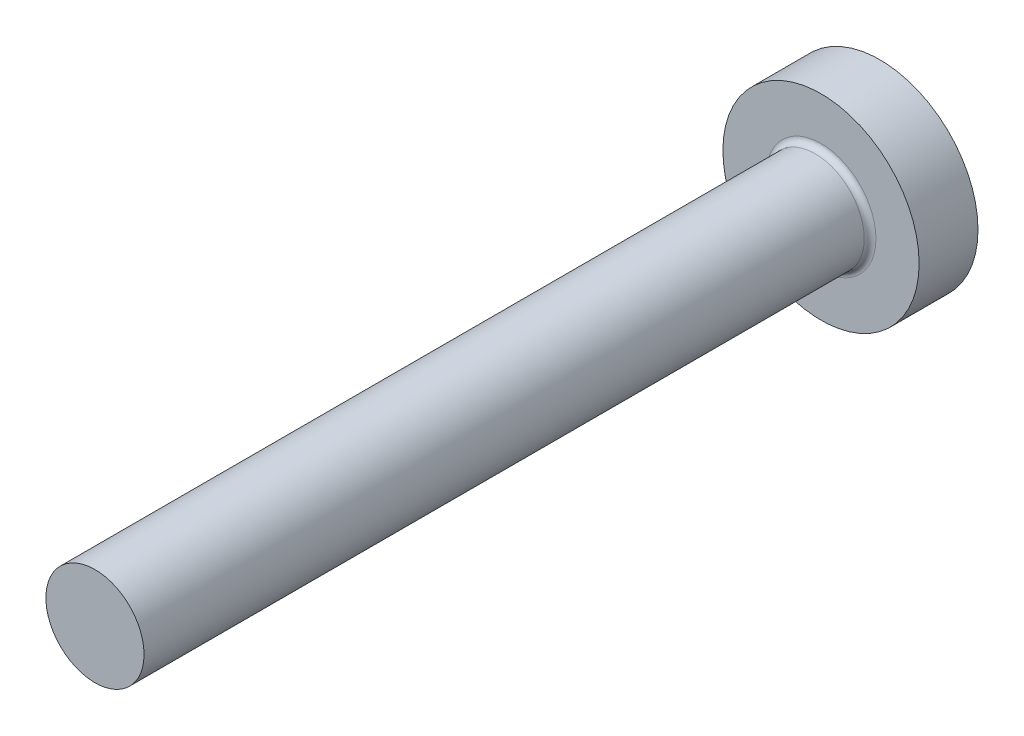
from build123d import *


with BuildPart() as part:
    # Skizze1 → Basis-Rotation (revolve)
    with BuildSketch(Plane(origin=(0, 0, 0), x_dir=(0, 0, -1), z_dir=(1, 0, 0)), mode=Mode.PRIVATE) as basis_rotation_sk:
        with BuildLine():
            Line((0, 0), (0, 5))
            Line((0, 5), (-3, 5))
            Line((-3, 5), (-3, 2.8))
            ThreePointArc((-3, 2.8), (-3.087867966, 2.587867966), (-3.3, 2.5))
            Line((-3.3, 2.5), (-40, 2.5))
            Line((-40, 2.5), (-40, 0))
            Line((-40, 0), (0, 0))
        make_face()
    revolve(basis_rotation_sk.sketch.rotate(Axis((0, 0, 0), (0, 0, -1)), 90), axis=Axis((0, 0, 0), (0, 0, -1)))  # turned: the seam where the file's is


solid = part.part
